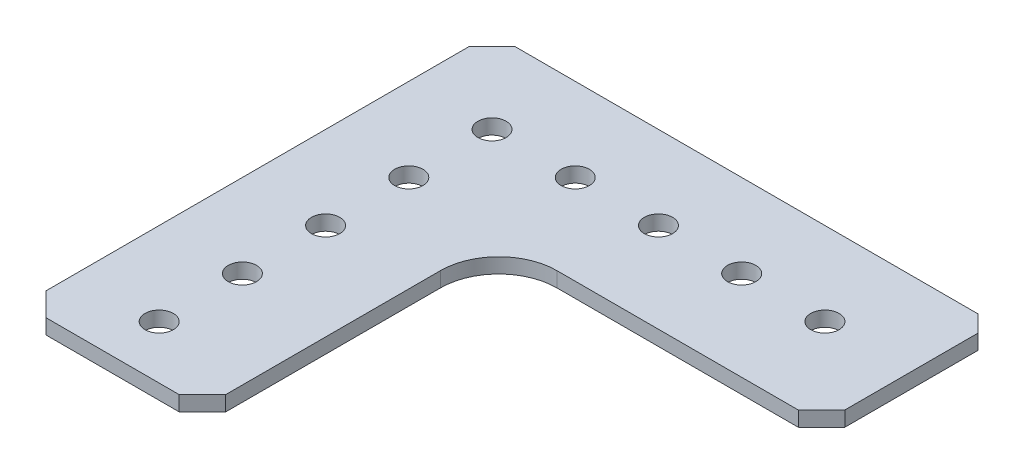
from build123d import *

# Parameters (mm, degrees)
BOSS_EXTRUDE1_DEPTH = 2.286
SKETCH2_R           = 2.159
CUT_EXTRUDE1_DEPTH  = 2.286


with BuildPart() as part:
    # Sketch1 → Boss-Extrude1 (new body)
    with BuildSketch(Plane(origin=(0, 0, 0), x_dir=(1, 0, 0), z_dir=(0, 1, 0))):
        with BuildLine():
            Line((-93.832484615, 46.752607692), (-93.832484615, -17.763392308))
            Line((-93.832484615, -17.763392308), (-90.276484615, -21.319392308))
            Line((-90.276484615, -21.319392308), (-69.956484615, -21.319392308))
            Line((-69.956484615, -21.319392308), (-66.400484615, -17.763392308))
            Line((-66.400484615, -17.763392308), (-66.400484615, 15.002607692))
            ThreePointArc((-66.400484615, 15.002607692), (-63.7966639, 21.288786977), (-57.510484615, 23.892607692))
            Line((-57.510484615, 23.892607692), (-20.680484615, 23.892607692))
            Line((-20.680484615, 23.892607692), (-17.124484615, 27.448607692))
            Line((-17.124484615, 27.448607692), (-17.124484615, 47.768607692))
            Line((-17.124484615, 47.768607692), (-19.664484615, 50.308607692))
            Line((-19.664484615, 50.308607692), (-90.276484615, 50.308607692))
            Line((-90.276484615, 50.308607692), (-93.832484615, 46.752607692))
        make_face()
    extrude(amount=BOSS_EXTRUDE1_DEPTH)

    # Sketch2 → Cut-Extrude1 (cut)
    with BuildSketch(Plane(origin=(0, 2.286, 0), x_dir=(1, 0, 0), z_dir=(0, 1, 0))):
        with Locations((-81.132484615, 37.608607692)):
            Circle(SKETCH2_R)
        with Locations((-81.132484615, 24.908607692)):
            Circle(SKETCH2_R)
        with Locations((-81.132484615, 12.208607692)):
            Circle(SKETCH2_R)
        with Locations((-81.132484615, -0.491392308)):
            Circle(SKETCH2_R)
        with Locations((-81.132484615, -13.191392308)):
            Circle(SKETCH2_R)
        with Locations((-68.432484615, 37.608607692)):
            Circle(SKETCH2_R)
        with Locations((-55.732484615, 37.608607692)):
            Circle(SKETCH2_R)
        with Locations((-43.032484615, 37.608607692)):
            Circle(SKETCH2_R)
        with Locations((-30.332484615, 37.608607692)):
            Circle(SKETCH2_R)
    extrude(amount=-CUT_EXTRUDE1_DEPTH, mode=Mode.SUBTRACT)


solid = part.part
